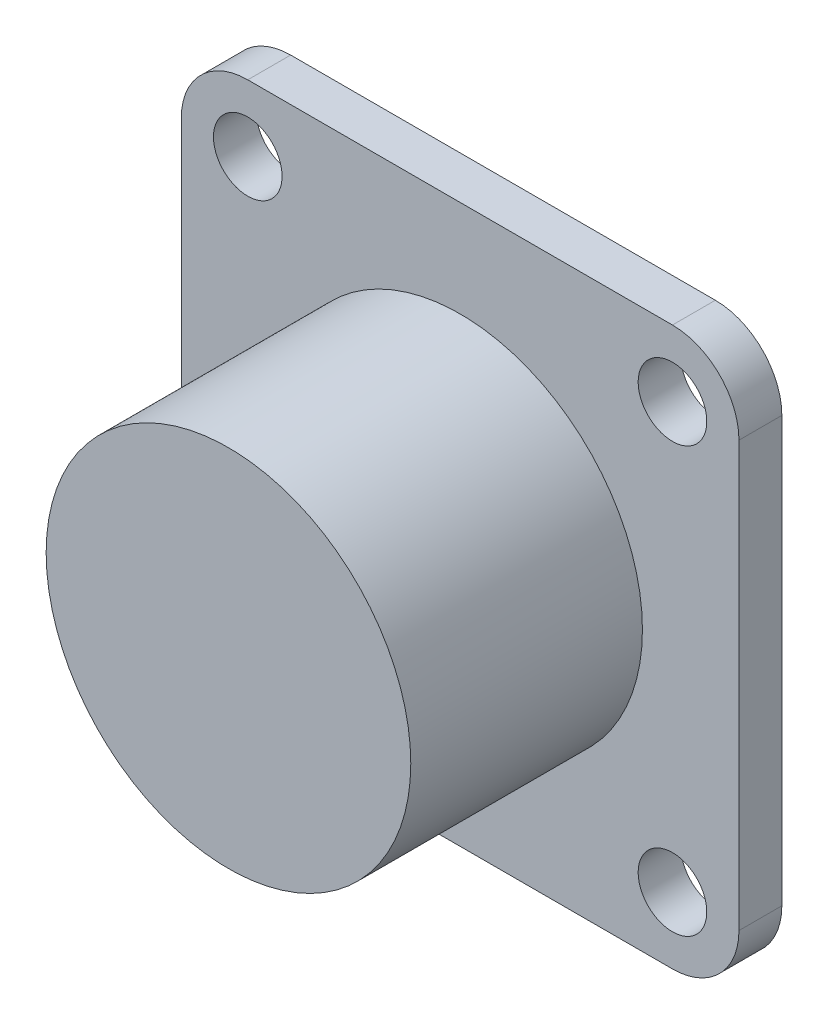
from build123d import *

# Parameters (mm, degrees)
SKETCH1_W                = 26
SKETCH1_H                = 26
BOSS_EXTRUDE1_DEPTH      = 2
FILLET1_R                = 3.1
SKETCH3_R                = 8.5
BOSS_EXTRUDE2_DEPTH      = 12.8
M3_CLEARANCE_HOLE1_D     = 3.2
M3_CLEARANCE_HOLE1_DEPTH = 5
M3_CLEARANCE_HOLE1_TIP   = 0.96137699
SKETCH7_R                = 8
SKETCH7_R_2              = 5.85
CUT_EXTRUDE1_DEPTH       = 11.8


with BuildPart() as part:
    # Sketch1 → Boss-Extrude1 (new body)
    with BuildSketch(Plane.XY):
        Rectangle(SKETCH1_W, SKETCH1_H)
    extrude(amount=BOSS_EXTRUDE1_DEPTH)

    # Fillet1
    fillet1_edges = [part.edges().sort_by_distance(p)[0] for p in [
        (13, -13, 1),
        (-13, -13, 1),
        (-13, 13, 1),
        (13, 13, 1),
    ]]
    fillet(fillet1_edges, radius=FILLET1_R)

    # Sketch3 → Boss-Extrude2 (add)
    with BuildSketch(Plane.XY):
        Circle(SKETCH3_R)
    extrude(amount=BOSS_EXTRUDE2_DEPTH)

    # M3 Clearance Hole1
    with Locations(Plane(origin=(0, 0, 0), x_dir=(-1, 0, 0), z_dir=(0, 0, -1))):
        with Locations((9.9, 9.9), (9.9, -9.9), (-9.9, -9.9), (-9.9, 9.9)):
            Hole(M3_CLEARANCE_HOLE1_D / 2, depth=M3_CLEARANCE_HOLE1_DEPTH)
            with Locations((0, 0, -(M3_CLEARANCE_HOLE1_DEPTH + M3_CLEARANCE_HOLE1_TIP / 2))):  # 118° drill point
                Cone(0, M3_CLEARANCE_HOLE1_D / 2, M3_CLEARANCE_HOLE1_TIP, mode=Mode.SUBTRACT)

    # Sketch7 → Cut-Extrude1 (cut)
    with BuildSketch(Plane(origin=(0, 0, 0), x_dir=(-1, 0, 0), z_dir=(0, 0, -1))):
        Circle(SKETCH7_R)
        Circle(SKETCH7_R_2, mode=Mode.SUBTRACT)
    extrude(amount=-CUT_EXTRUDE1_DEPTH, mode=Mode.SUBTRACT)


solid = part.part
